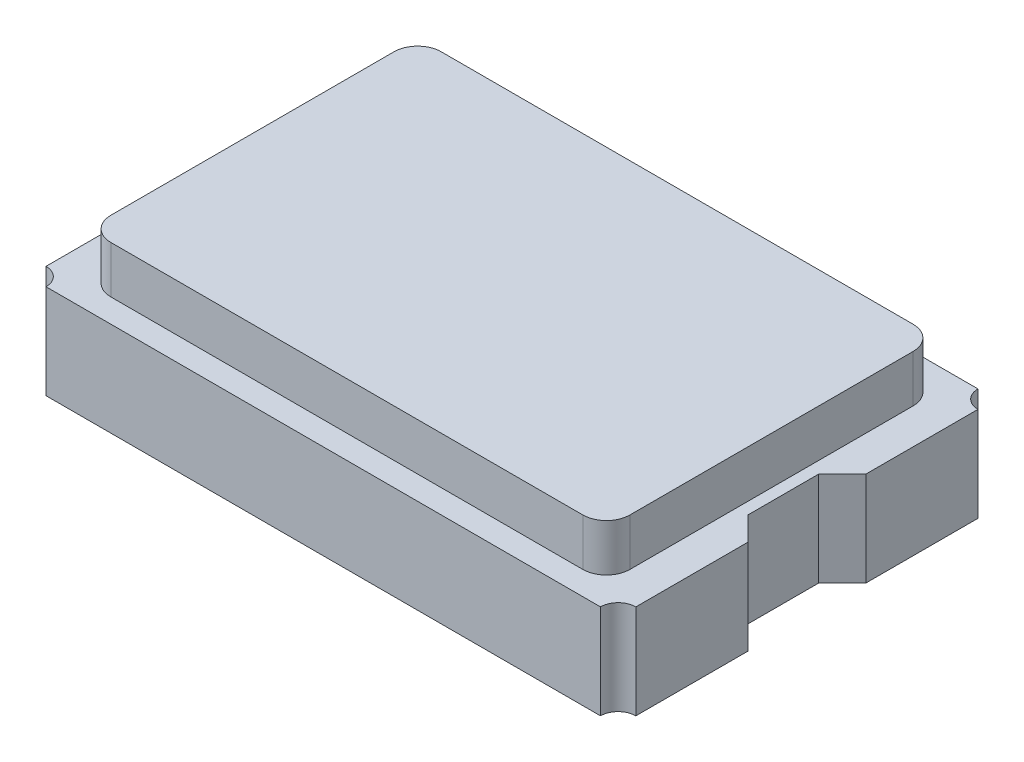
from build123d import *

# Parameters (mm, degrees)
SKETCH1_W           = 5
SKETCH1_H           = 3.2
BOSS_EXTRUDE1_DEPTH = 0.8
CUT_EXTRUDE1_REACH  = 2.8
SKETCH2_R           = 0.15
BOSS_EXTRUDE3_DEPTH = 0.4


with BuildPart() as part:
    # Sketch1 → Boss-Extrude1 (new body)
    with BuildSketch(Plane(origin=(0, 0, 0), x_dir=(1, 0, 0), z_dir=(0, 1, 0))):
        Rectangle(SKETCH1_W, SKETCH1_H)
    extrude(amount=BOSS_EXTRUDE1_DEPTH)

    # Sketch2 → Cut-Extrude1 (cut, up to next)
    with BuildSketch(Plane(origin=(0, 0.8, 0), x_dir=(1, 0, 0), z_dir=(0, 1, 0)), mode=Mode.PRIVATE) as cut_extrude1_sk1:
        with Locations((-2.5, 1.6)):
            Circle(SKETCH2_R)
    cut_extrude1_tool1 = extrude(cut_extrude1_sk1.sketch, amount=-CUT_EXTRUDE1_REACH, mode=Mode.PRIVATE) & part.part
    add(cut_extrude1_tool1.solids().sort_by_distance((-2.5, 0.8, -1.6))[0], mode=Mode.SUBTRACT)
    # Sketch2 → Cut-Extrude1 (cut, up to next)
    with BuildSketch(Plane(origin=(0, 0.8, 0), x_dir=(1, 0, 0), z_dir=(0, 1, 0)), mode=Mode.PRIVATE) as cut_extrude1_sk2:
        with Locations((2.5, 1.6)):
            Circle(SKETCH2_R)
    cut_extrude1_tool2 = extrude(cut_extrude1_sk2.sketch, amount=-CUT_EXTRUDE1_REACH, mode=Mode.PRIVATE) & part.part
    add(cut_extrude1_tool2.solids().sort_by_distance((2.5, 0.8, -1.6))[0], mode=Mode.SUBTRACT)
    # Sketch2 → Cut-Extrude1 (cut, up to next)
    with BuildSketch(Plane(origin=(0, 0.8, 0), x_dir=(1, 0, 0), z_dir=(0, 1, 0)), mode=Mode.PRIVATE) as cut_extrude1_sk3:
        with Locations((2.5, -1.6)):
            Circle(SKETCH2_R)
    cut_extrude1_tool3 = extrude(cut_extrude1_sk3.sketch, amount=-CUT_EXTRUDE1_REACH, mode=Mode.PRIVATE) & part.part
    add(cut_extrude1_tool3.solids().sort_by_distance((2.5, 0.8, 1.6))[0], mode=Mode.SUBTRACT)
    # Sketch2 → Cut-Extrude1 (cut, up to next)
    with BuildSketch(Plane(origin=(0, 0.8, 0), x_dir=(1, 0, 0), z_dir=(0, 1, 0)), mode=Mode.PRIVATE) as cut_extrude1_sk4:
        with Locations((-2.5, -1.6)):
            Circle(SKETCH2_R)
    cut_extrude1_tool4 = extrude(cut_extrude1_sk4.sketch, amount=-CUT_EXTRUDE1_REACH, mode=Mode.PRIVATE) & part.part
    add(cut_extrude1_tool4.solids().sort_by_distance((-2.5, 0.8, 1.6))[0], mode=Mode.SUBTRACT)
    # Sketch2 → Cut-Extrude1 (cut, up to next)
    with BuildSketch(Plane(origin=(0, 0.8, 0), x_dir=(1, 0, 0), z_dir=(0, 1, 0)), mode=Mode.PRIVATE) as cut_extrude1_sk5:
        Polygon((-2.3, -0.3), (-2.3, 0.3), (-2.5, 0.5), (-2.5, -0.5), align=None)
    cut_extrude1_tool5 = extrude(cut_extrude1_sk5.sketch, amount=-CUT_EXTRUDE1_REACH, mode=Mode.PRIVATE) & part.part
    add(cut_extrude1_tool5.solids().sort_by_distance((-2.408333, 0.8, 0))[0], mode=Mode.SUBTRACT)
    # Sketch2 → Cut-Extrude1 (cut, up to next)
    with BuildSketch(Plane(origin=(0, 0.8, 0), x_dir=(1, 0, 0), z_dir=(0, 1, 0)), mode=Mode.PRIVATE) as cut_extrude1_sk6:
        Polygon((2.3, -0.3), (2.5, -0.5), (2.5, 0.5), (2.3, 0.3), align=None)
    cut_extrude1_tool6 = extrude(cut_extrude1_sk6.sketch, amount=-CUT_EXTRUDE1_REACH, mode=Mode.PRIVATE) & part.part
    add(cut_extrude1_tool6.solids().sort_by_distance((2.408333, 0.8, 0))[0], mode=Mode.SUBTRACT)

    # Sketch3 → Boss-Extrude3 (add)
    with BuildSketch(Plane(origin=(0, 0.8, 0), x_dir=(1, 0, 0), z_dir=(0, 1, 0))):
        with BuildLine():
            Line((-2, -1.4), (2, -1.4))
            ThreePointArc((2, -1.4), (2.141421356, -1.341421356), (2.2, -1.2))
            Line((2.2, -1.2), (2.2, 1.2))
            ThreePointArc((2.2, 1.2), (2.141421356, 1.341421356), (2, 1.4))
            Line((2, 1.4), (-2, 1.4))
            ThreePointArc((-2, 1.4), (-2.141421356, 1.341421356), (-2.2, 1.2))
            Line((-2.2, 1.2), (-2.2, -1.2))
            ThreePointArc((-2.2, -1.2), (-2.141421356, -1.341421356), (-2, -1.4))
        make_face()
    extrude(amount=BOSS_EXTRUDE3_DEPTH)


solid = part.part
